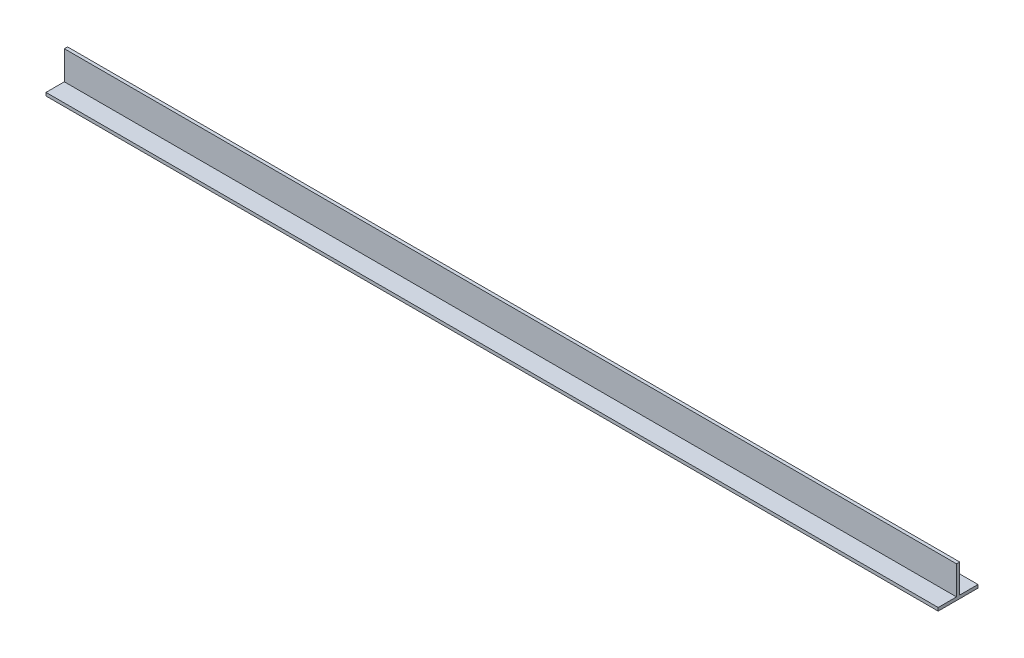
from build123d import *

# Parameters (mm, degrees)
BOSS_EXTRUDE1_DEPTH = 355.6
CUT_EXTRUDE1_REACH  = 3.27
SKETCH2_R           = 2.15265


with BuildPart() as part:
    # Sketch1 → Boss-Extrude1 (new body)
    with BuildSketch(Plane(origin=(0, 0, 0), x_dir=(0, 0, -1), z_dir=(1, 0, 0))):
        Polygon((0.635, 0), (7.9375, 0), (7.9375, -1.27), (-7.9375, -1.27), (-7.9375, 0), (-0.635, 0), (-0.635, 11.43), (0.635, 11.43), align=None)
    extrude(amount=BOSS_EXTRUDE1_DEPTH)

    # Sketch2 → Cut-Extrude1 (cut, up to next)
    with BuildSketch(Plane(origin=(0, 0, 0), x_dir=(1, 0, 0), z_dir=(0, 1, 0)), mode=Mode.PRIVATE) as cut_extrude1_sk1:
        with Locations((25.4, 4.28625)):
            Circle(SKETCH2_R)
    cut_extrude1_tool1 = extrude(cut_extrude1_sk1.sketch, amount=-CUT_EXTRUDE1_REACH, mode=Mode.PRIVATE) & part.part
    add(cut_extrude1_tool1.solids().sort_by_distance((25.4, 0, -4.28625))[0], mode=Mode.SUBTRACT)
    # Sketch2 → Cut-Extrude1 (cut, up to next)
    with BuildSketch(Plane(origin=(0, 0, 0), x_dir=(1, 0, 0), z_dir=(0, 1, 0)), mode=Mode.PRIVATE) as cut_extrude1_sk2:
        with Locations((127, 4.28625)):
            Circle(SKETCH2_R)
    cut_extrude1_tool2 = extrude(cut_extrude1_sk2.sketch, amount=-CUT_EXTRUDE1_REACH, mode=Mode.PRIVATE) & part.part
    add(cut_extrude1_tool2.solids().sort_by_distance((127, 0, -4.28625))[0], mode=Mode.SUBTRACT)
    # Sketch2 → Cut-Extrude1 (cut, up to next)
    with BuildSketch(Plane(origin=(0, 0, 0), x_dir=(1, 0, 0), z_dir=(0, 1, 0)), mode=Mode.PRIVATE) as cut_extrude1_sk3:
        with Locations((228.6, 4.28625)):
            Circle(SKETCH2_R)
    cut_extrude1_tool3 = extrude(cut_extrude1_sk3.sketch, amount=-CUT_EXTRUDE1_REACH, mode=Mode.PRIVATE) & part.part
    add(cut_extrude1_tool3.solids().sort_by_distance((228.6, 0, -4.28625))[0], mode=Mode.SUBTRACT)
    # Sketch2 → Cut-Extrude1 (cut, up to next)
    with BuildSketch(Plane(origin=(0, 0, 0), x_dir=(1, 0, 0), z_dir=(0, 1, 0)), mode=Mode.PRIVATE) as cut_extrude1_sk4:
        with Locations((330.2, 4.28625)):
            Circle(SKETCH2_R)
    cut_extrude1_tool4 = extrude(cut_extrude1_sk4.sketch, amount=-CUT_EXTRUDE1_REACH, mode=Mode.PRIVATE) & part.part
    add(cut_extrude1_tool4.solids().sort_by_distance((330.2, 0, -4.28625))[0], mode=Mode.SUBTRACT)


solid = part.part
